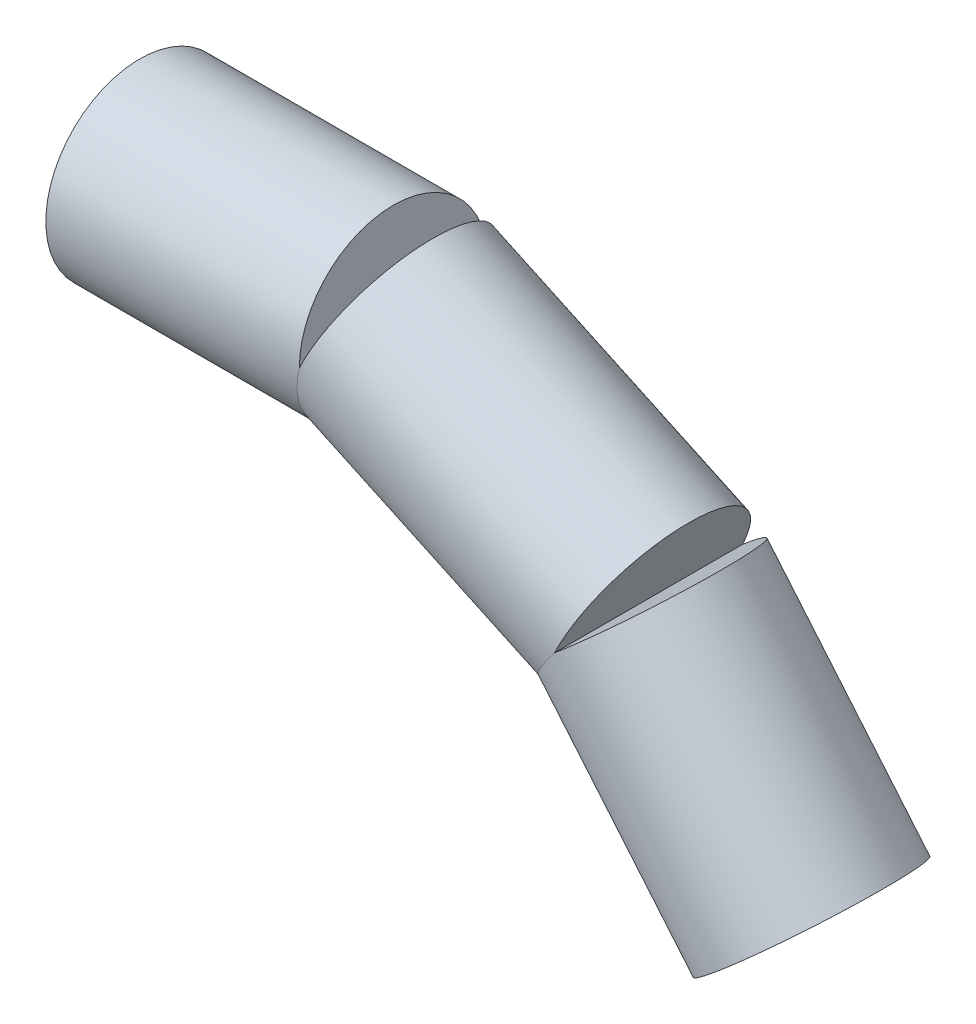
from build123d import *

# Parameters (mm, degrees)
SKETCH4_R           = 16.9545
BOSS_EXTRUDE1_DEPTH = 45.72
SKETCH5_R           = 16.9545
BOSS_EXTRUDE2_DEPTH = 50.8
SKETCH9_R           = 16.9545
BOSS_EXTRUDE3_DEPTH = 45.72
SKETCH10_R          = 9.525
CUT_EXTRUDE1_DEPTH  = 12.7
SKETCH12_R          = 9.525
CUT_EXTRUDE2_DEPTH  = 12.7


with BuildPart() as part:
    # Sketch4 → Boss-Extrude1 (new body)
    with BuildSketch(Plane(origin=(0, 0, 0), x_dir=(0, 0, -1), z_dir=(1, 0, 0))):
        Circle(SKETCH4_R)
    extrude(amount=BOSS_EXTRUDE1_DEPTH)

    # Sketch5 → Boss-Extrude2 (add)
    with BuildSketch(Plane(origin=(45.72, 0, 0), x_dir=(0, 0, -1), z_dir=(0.906307787, -0.422618262, 0))):
        Circle(SKETCH5_R)
    extrude(amount=BOSS_EXTRUDE2_DEPTH)

    # Sketch9 → Boss-Extrude3 (add)
    with BuildSketch(Plane(origin=(91.760435581, -21.469007696, 0), x_dir=(0.766044443, 0.64278761, 0), z_dir=(-0.64278761, 0.766044443, 0))):
        Circle(SKETCH9_R)
    extrude(amount=-BOSS_EXTRUDE3_DEPTH)

    # Sketch10 → Cut-Extrude1 (cut)
    with BuildSketch(Plane(origin=(77.87287371, -92.805277009, 0), x_dir=(0.766044443, 0.64278761, 0), z_dir=(0.64278761, -0.766044443, 0))):
        with Locations((56.492559636, 0)):
            Circle(SKETCH10_R)
    extrude(amount=-CUT_EXTRUDE1_DEPTH, mode=Mode.SUBTRACT)

    # Sketch12 → Cut-Extrude2 (cut)
    with BuildSketch(Plane.ZY):
        Circle(SKETCH12_R)
    extrude(amount=-CUT_EXTRUDE2_DEPTH, mode=Mode.SUBTRACT)


solid = part.part
